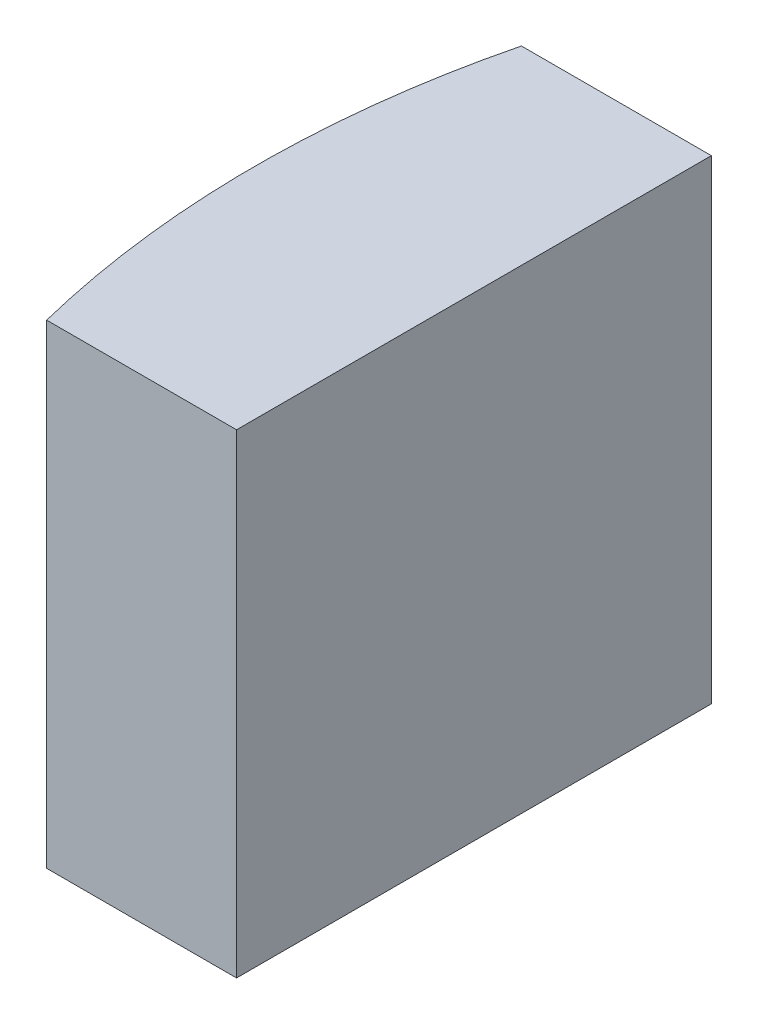
from build123d import *

# Parameters (mm, degrees)
EXTRUDE_1_DEPTH = 5


with BuildPart() as part:
    # 草图1 → 凸台-拉伸1 (new body)
    with BuildSketch(Plane(origin=(0, 0, 0), x_dir=(1, 0, 0), z_dir=(0, 1, 0))):
        with BuildLine():
            Line((0, 0), (0, -5))
            Line((0, -5), (-2, -5))
            ThreePointArc((-2, -5), (-2.307081263, -2.5), (-2, 0))
            Line((-2, 0), (0, 0))
        make_face()
    extrude(amount=EXTRUDE_1_DEPTH)


solid = part.part
